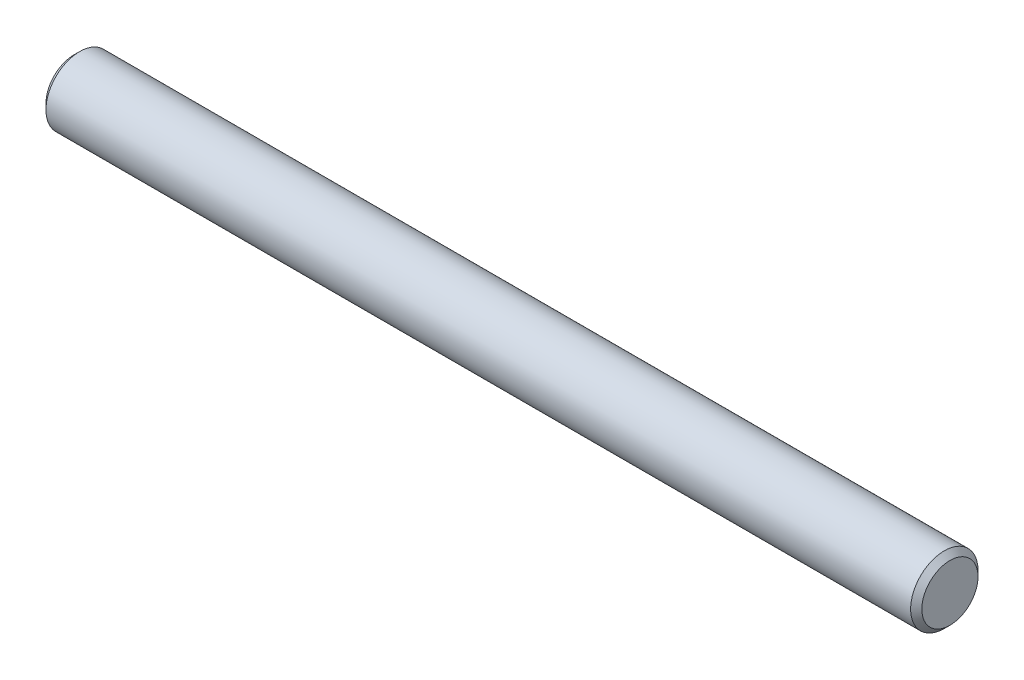
from build123d import *

# Parameters (mm, degrees)
SKIZZE1_R                       = 3
AUFSATZ_LINEAR_AUSTRAGEN1_DEPTH = 39
FASE1_SIZE                      = 0.5


with BuildPart() as part:
    # Skizze1 → Aufsatz-Linear austragen1 (new body, symmetric)
    with BuildSketch(Plane(origin=(0, 0, 0), x_dir=(0, 0, -1), z_dir=(1, 0, 0))):
        Circle(SKIZZE1_R)
    extrude(amount=AUFSATZ_LINEAR_AUSTRAGEN1_DEPTH, both=True)

    # Fase1
    fase1_edges = [part.edges().sort_by_distance(p)[0] for p in [
        (-39, 0, 3),
        (39, 0, 3),
    ]]
    chamfer(fase1_edges, length=FASE1_SIZE)


solid = part.part
